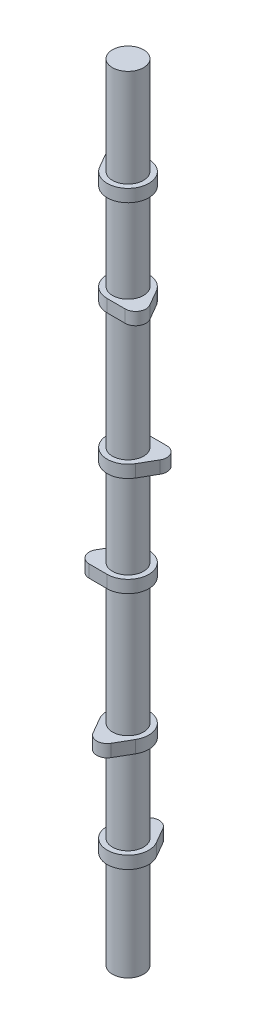
from build123d import *

# Parameters (mm, degrees)
BOSS_EXTRUDE1_DEPTH   = 3.81
LPATTERN1_COUNT       = 2
LPATTERN1_PITCH       = 60.96
BODY_MOVE_COPY1_ANGLE = 180
LPATTERN2_COUNT       = 3
LPATTERN2_PITCH       = 146.05
BODY_MOVE_COPY2_ANGLE = 120
BODY_MOVE_COPY3_ANGLE = 120
BOSS_EXTRUDE2_START   = -63.5
SKETCH2_R             = 9.5
BOSS_EXTRUDE2_DEPTH   = 480.06


with BuildPart() as part:
    # Sketch1 → Boss-Extrude1 (new, symmetric)
    with BuildSketch(Plane(origin=(0, 0, 0), x_dir=(1, 0, 0), z_dir=(0, 1, 0))):
        with BuildLine():
            Line((-5.499261314, 15.875), (-10.998522628, 6.35))
            ThreePointArc((-10.998522628, 6.35), (0, -12.7), (10.998522628, 6.35))
            Line((10.998522628, 6.35), (5.499261314, 15.875))
            ThreePointArc((5.499261314, 15.875), (0, 19.05), (-5.499261314, 15.875))
        make_face()
    extrude(amount=BOSS_EXTRUDE1_DEPTH, both=True)


with BuildPart() as lpattern1_1:
    # LPattern1: pattern copy
    add(part.part.moved(Location(Vector(0, 1, 0) * (1 * LPATTERN1_PITCH))))


with BuildPart() as lpattern1_1_1:
    # Body-Move_Copy1: moved
    add(lpattern1_1.part.rotate(Axis((0, 0, 0), (0, 1, 0)), BODY_MOVE_COPY1_ANGLE))


with BuildPart() as lpattern2_1:
    # LPattern2: pattern copy
    add(part.part.moved(Location(Vector(0, 1, 0) * (1 * LPATTERN2_PITCH))))


with BuildPart() as lpattern2_2:
    # LPattern2: pattern copy
    add(part.part.moved(Location(Vector(0, 1, 0) * (2 * LPATTERN2_PITCH))))


with BuildPart() as lpattern2_3:
    # LPattern2: pattern copy
    add(lpattern1_1_1.part.moved(Location(Vector(0, 1, 0) * (1 * LPATTERN2_PITCH))))


with BuildPart() as lpattern2_4:
    # LPattern2: pattern copy
    add(lpattern1_1_1.part.moved(Location(Vector(0, 1, 0) * (2 * LPATTERN2_PITCH))))


with BuildPart() as lpattern2_3_1:
    # Body-Move_Copy2: moved
    add(lpattern2_3.part.rotate(Axis((0, 0, 0), (0, 1, 0)), BODY_MOVE_COPY2_ANGLE))


with BuildPart() as lpattern2_1_1:
    # Body-Move_Copy2: moved
    add(lpattern2_1.part.rotate(Axis((0, 0, 0), (0, 1, 0)), BODY_MOVE_COPY2_ANGLE))


with BuildPart() as lpattern2_4_1:
    # Body-Move_Copy3: moved
    add(lpattern2_4.part.rotate(Axis((0, 0, 0), (0, -1, 0)), BODY_MOVE_COPY3_ANGLE))


with BuildPart() as lpattern2_2_1:
    # Body-Move_Copy3: moved
    add(lpattern2_2.part.rotate(Axis((0, 0, 0), (0, -1, 0)), BODY_MOVE_COPY3_ANGLE))


with BuildPart() as part_1:
    add(part.part)

    # Sketch2 → Boss-Extrude2 (add)
    with BuildSketch(Plane(origin=(0, 0, 0), x_dir=(1, 0, 0), z_dir=(0, 1, 0)).offset(BOSS_EXTRUDE2_START)):
        Circle(SKETCH2_R)
    extrude(amount=BOSS_EXTRUDE2_DEPTH)


with BuildPart() as lpattern1_1_2:
    add(lpattern1_1_1.part)

    # Combine1: union LPattern2_3, LPattern2_1, LPattern2_4, LPattern2_2, part
    add(lpattern2_3_1.part)
    add(lpattern2_1_1.part)
    add(lpattern2_4_1.part)
    add(lpattern2_2_1.part)
    add(part_1.part)


solid = lpattern1_1_2.part
